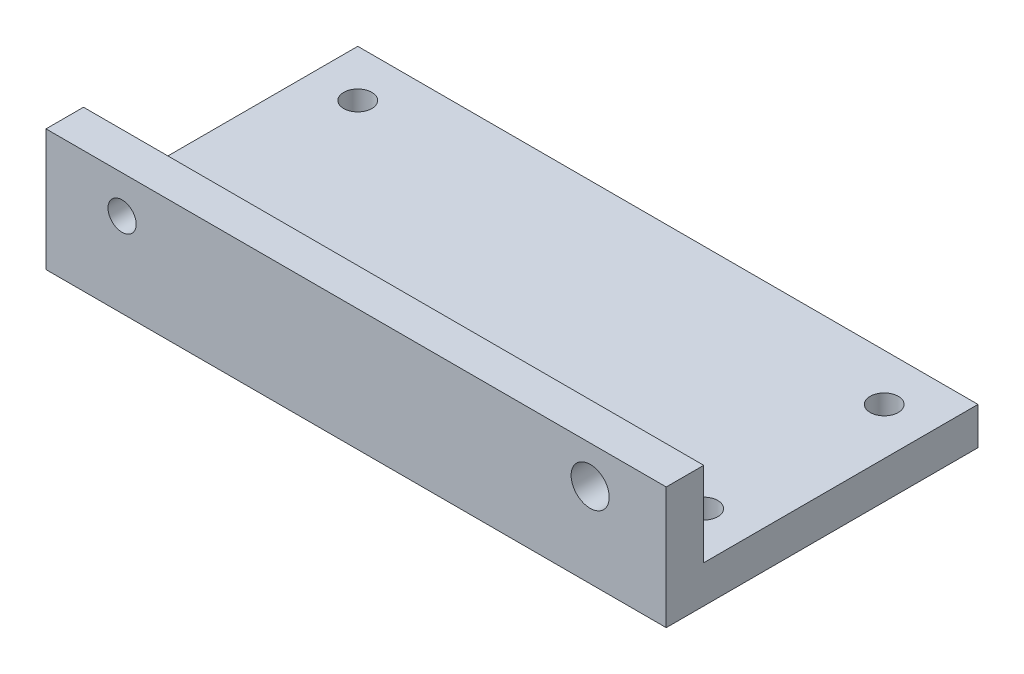
from build123d import *

# Parameters (mm, degrees)
SKETCH1_W           = 66.15
SKETCH1_H           = 4
SKETCH1_H_2         = 29.25
SKETCH1_R           = 1.5
BOSS_EXTRUDE1_DEPTH = 4
BOSS_EXTRUDE2_START = 4
SKETCH1_3_W         = 66.15
SKETCH1_3_H         = 4
BOSS_EXTRUDE2_DEPTH = 9
SKETCH2_R           = 1.5
SKETCH2_R_2         = 2.031128953
CUT_EXTRUDE1_DEPTH  = 9


with BuildPart() as part:
    # Sketch1 → Boss-Extrude1 (new body)
    with BuildSketch(Plane(origin=(0, 0, 0), x_dir=(1, 0, 0), z_dir=(0, 1, 0))):
        with Locations((0, -16.625)):
            Rectangle(SKETCH1_W, SKETCH1_H)
        Rectangle(SKETCH1_W, SKETCH1_H_2)
        with Locations((28.075, 9.625)):
            Circle(SKETCH1_R, mode=Mode.SUBTRACT)
        with Locations((28.075, -9.625)):
            Circle(SKETCH1_R, mode=Mode.SUBTRACT)
        with Locations((-28.075, -9.625)):
            Circle(SKETCH1_R, mode=Mode.SUBTRACT)
        with Locations((-28.075, 9.625)):
            Circle(SKETCH1_R, mode=Mode.SUBTRACT)
    extrude(amount=BOSS_EXTRUDE1_DEPTH)

    # Sketch1_3 → Boss-Extrude2 (add)
    with BuildSketch(Plane(origin=(0, 0, 0), x_dir=(1, 0, 0), z_dir=(0, 1, 0)).offset(BOSS_EXTRUDE2_START)):
        with Locations((0, -16.625)):
            Rectangle(SKETCH1_3_W, SKETCH1_3_H)
    extrude(amount=BOSS_EXTRUDE2_DEPTH)

    # Sketch2 → Cut-Extrude1 (cut)
    with BuildSketch(Plane.XY.offset(18.625)):
        with Locations((-24.96, 9)):
            Circle(SKETCH2_R)
        with Locations((24.96, 9)):
            Circle(SKETCH2_R_2)
    extrude(amount=-CUT_EXTRUDE1_DEPTH, mode=Mode.SUBTRACT)


solid = part.part
